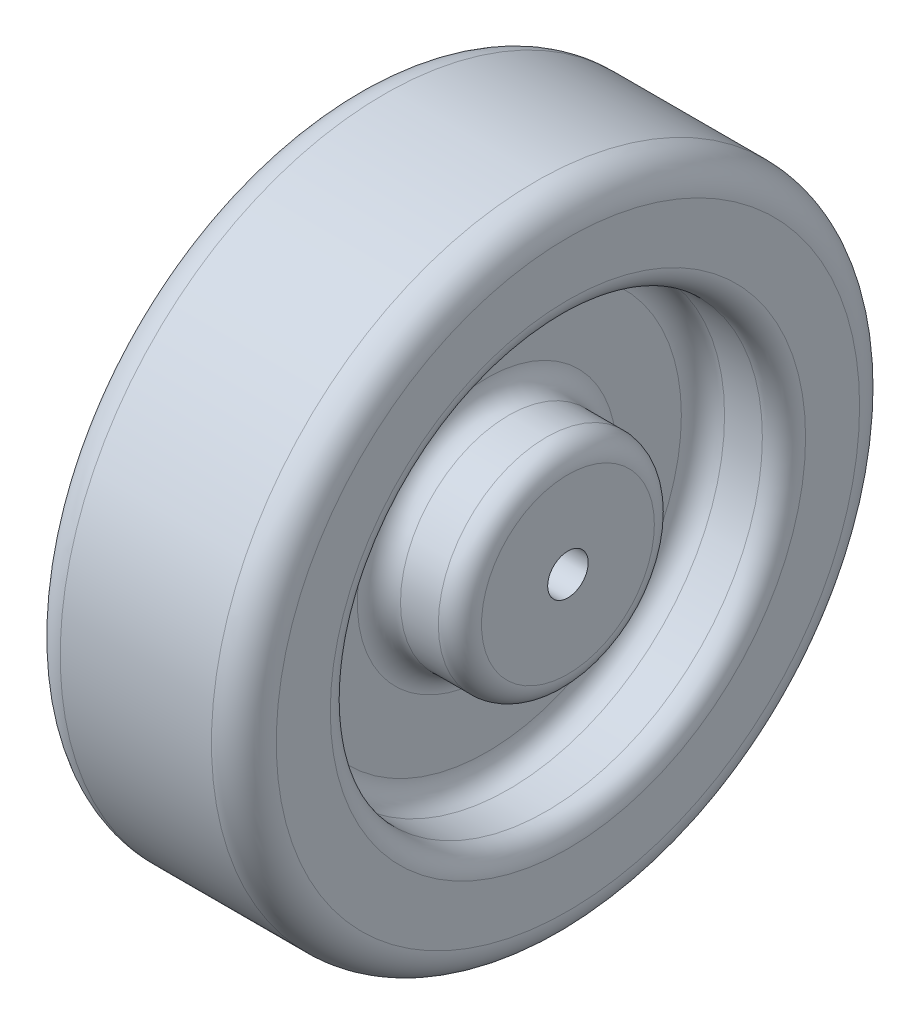
from build123d import *

# Parameters (mm, degrees)
SKETCH1_R           = 76.2
BOSS_EXTRUDE1_DEPTH = 50.8
SKETCH2_R           = 50.8
SKETCH2_R_2         = 25.4
CUT_EXTRUDE1_DEPTH  = 19.05
SKETCH3_R           = 50.8
SKETCH3_R_2         = 25.4
CUT_EXTRUDE2_DEPTH  = 19.05
SKETCH4_R           = 4.7625
CUT_EXTRUDE3_DEPTH  = 51.8
FILLET1_R           = 7.62
FILLET2_R           = 5.08


with BuildPart() as part:
    # Sketch1 → Boss-Extrude1 (new body)
    with BuildSketch(Plane(origin=(0, 0, 0), x_dir=(0, 0, -1), z_dir=(1, 0, 0))):
        Circle(SKETCH1_R)
    extrude(amount=BOSS_EXTRUDE1_DEPTH)

    # Sketch2 → Cut-Extrude1 (cut)
    with BuildSketch(Plane(origin=(50.8, 0, 0), x_dir=(0, 0, -1), z_dir=(1, 0, 0))):
        Circle(SKETCH2_R)
        Circle(SKETCH2_R_2, mode=Mode.SUBTRACT)
    extrude(amount=-CUT_EXTRUDE1_DEPTH, mode=Mode.SUBTRACT)

    # Sketch3 → Cut-Extrude2 (cut)
    with BuildSketch(Plane.ZY):
        Circle(SKETCH3_R)
        Circle(SKETCH3_R_2, mode=Mode.SUBTRACT)
    extrude(amount=-CUT_EXTRUDE2_DEPTH, mode=Mode.SUBTRACT)

    # Sketch4 → Cut-Extrude3 (cut, through all)
    with BuildSketch(Plane.ZY):
        Circle(SKETCH4_R)
    extrude(amount=-CUT_EXTRUDE3_DEPTH, mode=Mode.SUBTRACT)

    # Fillet1
    fillet1_edges = [part.edges().sort_by_distance(p)[0] for p in [
        (0, 0, 76.2),
        (50.8, 0, 76.2),
    ]]
    fillet(fillet1_edges, radius=FILLET1_R)

    # Fillet2
    fillet2_edges = [part.edges().sort_by_distance(p)[0] for p in [
        (19.05, 0, -50.8),
        (19.05, 0, -25.4),
        (0, 0, -50.8),
        (0, 0, -25.4),
        (31.75, 0, 50.8),
        (31.75, 0, 25.4),
        (50.8, 0, 50.8),
        (50.8, 0, 25.4),
    ]]
    fillet(fillet2_edges, radius=FILLET2_R)


solid = part.part
